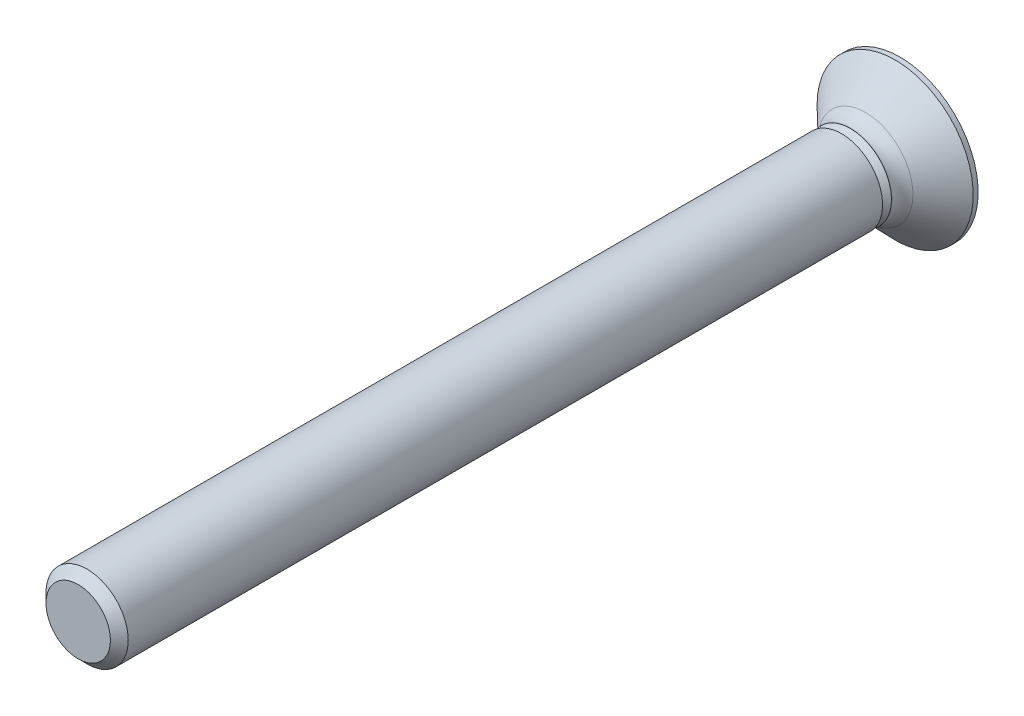
from build123d import *

# Parameters (mm, degrees)
SKETCH1_W           = 1
SKETCH1_H           = 18.5735
SKETCH2_R           = 0.7835
BOSS_EXTRUDE1_DEPTH = 0.2165
BOSS_EXTRUDE1_TAPER = -45
SKETCH3_R           = 1
BOSS_EXTRUDE2_DEPTH = 0.222374751
SKETCH4_R           = 1
BOSS_EXTRUDE3_DEPTH = 0.867625249
BOSS_EXTRUDE3_TAPER = -46.049277384
SKETCH5_R           = 1.9
BOSS_EXTRUDE4_DEPTH = 0.12
CUT_EXTRUDE1_DEPTH  = 0.9
CUT_EXTRUDE1_TAPER  = 15
CHAMFER1_SIZE       = 0.2165
FILLET1_R           = 0.5
SCALE1_SCALE        = 3.125


with BuildPart() as part:
    # Sketch1 → Revolve1 (revolve)
    with BuildSketch(Plane.XZ):
        with Locations((0.5, 10.71325)):
            Rectangle(SKETCH1_W, SKETCH1_H)
    revolve(axis=Axis((0, 0, 20), (0, 0, -1)))

    # Sketch2 → Boss-Extrude1 (add)
    with BuildSketch(Plane(origin=(0, 0, 1.4265), x_dir=(-1, 0, 0), z_dir=(0, 0, -1))):
        Circle(SKETCH2_R)
    extrude(amount=BOSS_EXTRUDE1_DEPTH, taper=BOSS_EXTRUDE1_TAPER)

    # Sketch3 → Boss-Extrude2 (add)
    with BuildSketch(Plane(origin=(0, 0, 1.21), x_dir=(-1, 0, 0), z_dir=(0, 0, -1))):
        Circle(SKETCH3_R)
    extrude(amount=BOSS_EXTRUDE2_DEPTH)

    # Sketch4 → Boss-Extrude3 (add)
    with BuildSketch(Plane(origin=(0, 0, 0.987625249), x_dir=(-1, 0, 0), z_dir=(0, 0, -1))):
        Circle(SKETCH4_R)
    extrude(amount=BOSS_EXTRUDE3_DEPTH, taper=BOSS_EXTRUDE3_TAPER)

    # Sketch5 → Boss-Extrude4 (add)
    with BuildSketch(Plane(origin=(0, 0, 0.12), x_dir=(-1, 0, 0), z_dir=(0, 0, -1))):
        Circle(SKETCH5_R)
    extrude(amount=BOSS_EXTRUDE4_DEPTH)

    # Sketch6 → Cut-Extrude1 (cut)
    with BuildSketch(Plane(origin=(0, 0, 0), x_dir=(-1, 0, 0), z_dir=(0, 0, -1))):
        Polygon((-0.95, -0.158333333), (-0.410095116, -0.410095116), (-0.158333333, -0.95), (0.158333333, -0.95), (0.410095116, -0.410095116), (0.95, -0.158333333), (0.95, 0.158333333), (0.410095116, 0.410095116), (0.158333333, 0.95), (-0.158333333, 0.95), (-0.410095116, 0.410095116), (-0.95, 0.158333333), align=None)
    extrude(amount=-CUT_EXTRUDE1_DEPTH, taper=CUT_EXTRUDE1_TAPER, mode=Mode.SUBTRACT)

    # Chamfer1
    chamfer1_edges = [part.edges().sort_by_distance(p)[0] for p in [
        (-1, 0, 20),
    ]]
    chamfer(chamfer1_edges, length=CHAMFER1_SIZE)

    # Fillet1
    fillet1_edges = [part.edges().sort_by_distance(p)[0] for p in [
        (1, 0, 0.987625249),
    ]]
    fillet(fillet1_edges, radius=FILLET1_R)


with BuildPart() as part_1:
    # Scale1: scaled about (8e-09, 0, 9.540596362)
    add(part.part.scale(SCALE1_SCALE).moved(Location((-1.7e-08, 0, -20.273767269))))


solid = part_1.part
